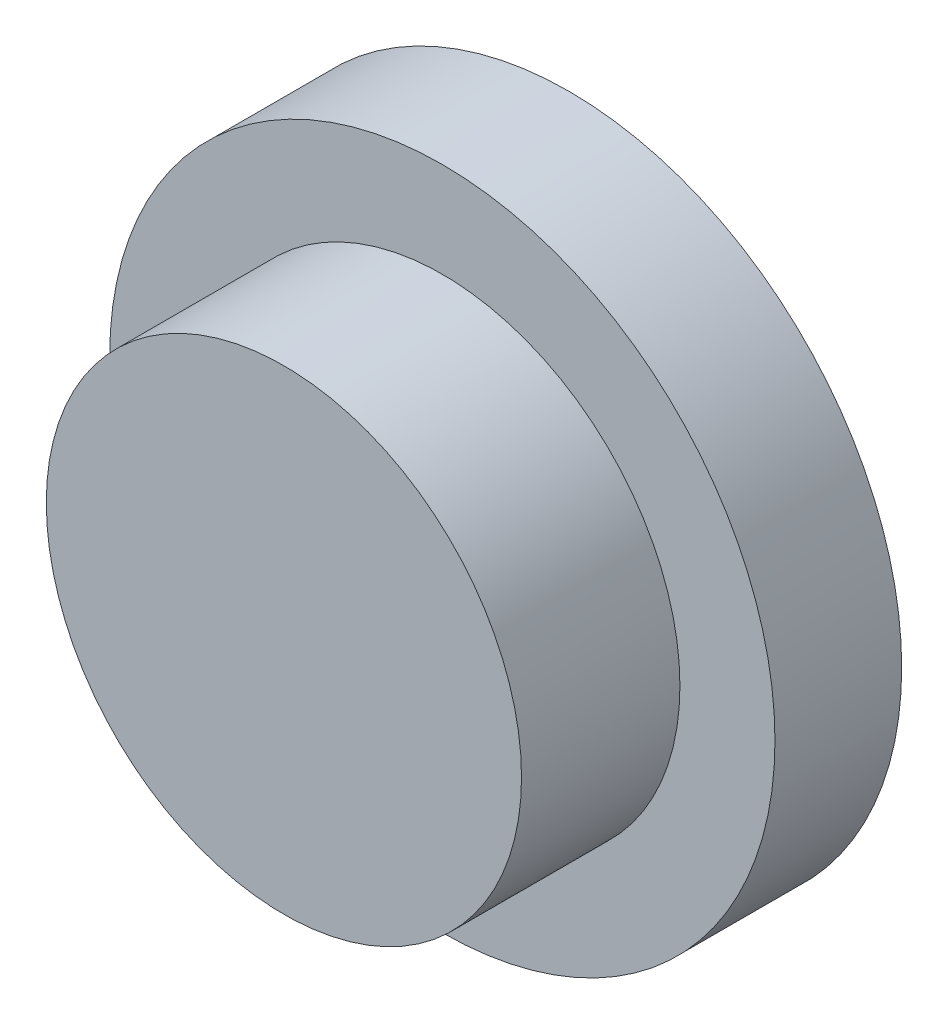
from build123d import *

# Parameters (mm, degrees)
SKETCH1_R           = 7.5
BOSS_EXTRUDE1_DEPTH = 5
SKETCH3_R           = 10.5
BOSS_EXTRUDE2_DEPTH = 4
SKETCH4_R           = 8.25
CUT_EXTRUDE1_DEPTH  = 3
CHAMFER1_SIZE       = 0.5


with BuildPart() as part:
    # Sketch1 → Boss-Extrude1 (new body)
    with BuildSketch(Plane.XY):
        Circle(SKETCH1_R)
    extrude(amount=BOSS_EXTRUDE1_DEPTH)

    # Sketch3 → Boss-Extrude2 (add)
    with BuildSketch(Plane(origin=(0, 0, 0), x_dir=(-1, 0, 0), z_dir=(0, 0, -1))):
        Circle(SKETCH3_R)
    extrude(amount=BOSS_EXTRUDE2_DEPTH)

    # Sketch4 → Cut-Extrude1 (cut)
    with BuildSketch(Plane(origin=(0, 0, -4), x_dir=(-1, 0, 0), z_dir=(0, 0, -1))):
        Circle(SKETCH4_R)
    extrude(amount=-CUT_EXTRUDE1_DEPTH, mode=Mode.SUBTRACT)

    # Chamfer1
    chamfer1_edges = [part.edges().sort_by_distance(p)[0] for p in [
        (8.25, 0, -4),
    ]]
    chamfer(chamfer1_edges, length=CHAMFER1_SIZE)


solid = part.part
